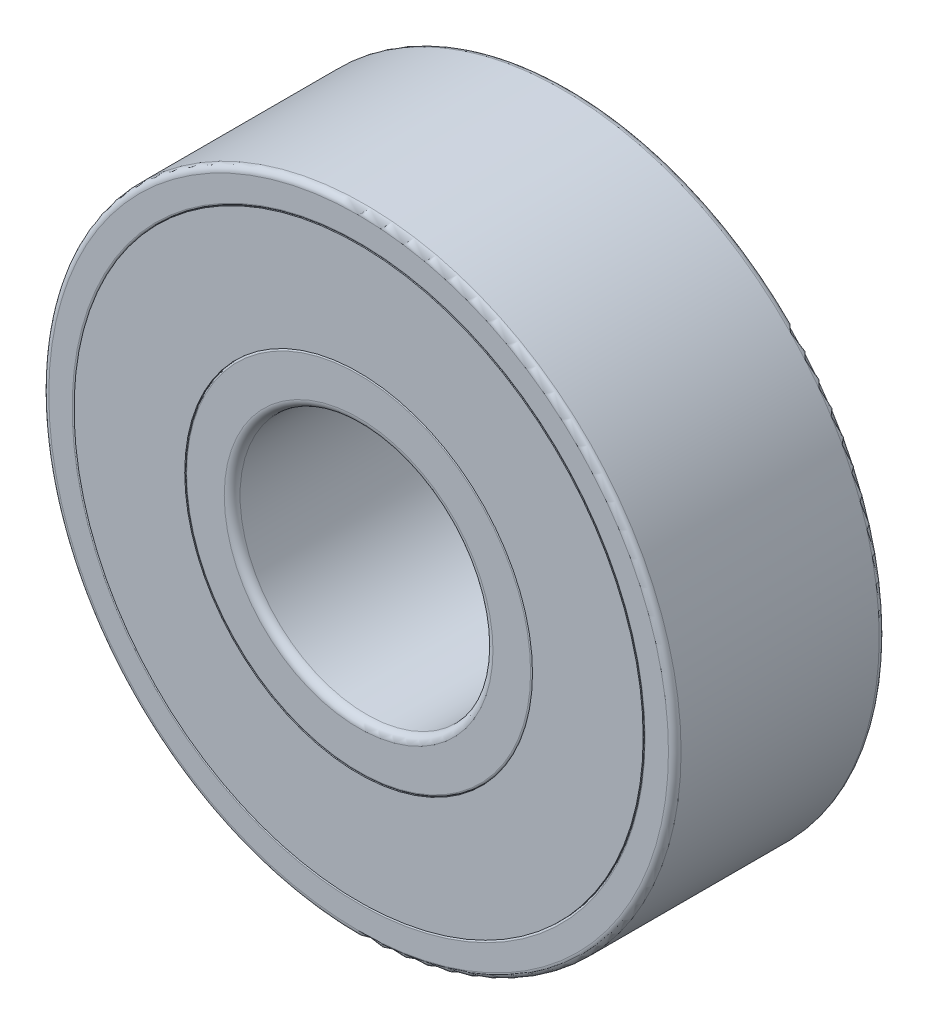
from build123d import *

# Parameters (mm, degrees)
SKETCH3_W           = 5
SKETCH3_H           = 0.75
SKETCH3_H_2         = 1.125
SKETCH4_R           = 1.575
CIRPATTERN1_COUNT   = 7
FILLET1_R           = 0.15
FILLET2_R           = 0.1875
FILLET3_R           = 0.045
FILLET4_R           = 0.045
SKETCH6_R           = 6.75
SKETCH6_R_2         = 4.125
BOSS_EXTRUDE2_DEPTH = 2.5


with BuildPart() as part:
    # Sketch3 → Revolve1 (revolve)
    with BuildSketch(Plane(origin=(0, 0, 0), x_dir=(0, 0, -1), z_dir=(1, 0, 0))):
        with Locations((0, -7.125)):
            Rectangle(SKETCH3_W, SKETCH3_H)
        with Locations((0, -3.5625)):
            Rectangle(SKETCH3_W, SKETCH3_H_2)
    revolve(axis=Axis((0, 0, 2.5), (0, 0, -1)))

    # Sketch4 → Cut-Revolve1 (revolve, cut)
    with BuildSketch(Plane(origin=(0, 0, 0), x_dir=(0, 0, -1), z_dir=(1, 0, 0))):
        with Locations((0, -5.4375)):
            Circle(SKETCH4_R)
    revolve(axis=Axis((0, 0, 2.5), (0, 0, -1)), mode=Mode.SUBTRACT)

    # Fillet1
    fillet1_edges = [part.edges().sort_by_distance(p)[0] for p in [
        (0, 7.5, -2.5),
        (0, 7.5, 2.5),
    ]]
    fillet(fillet1_edges, radius=FILLET1_R)

    # Fillet2
    fillet2_edges = [part.edges().sort_by_distance(p)[0] for p in [
        (0, 3, -2.5),
        (0, 3, 2.5),
    ]]
    fillet(fillet2_edges, radius=FILLET2_R)

    # Fillet3
    fillet3_edges = [part.edges().sort_by_distance(p)[0] for p in [
        (0, 6.75, 2.5),
        (0, 6.75, -2.5),
    ]]
    fillet(fillet3_edges, radius=FILLET3_R)

    # Fillet4
    fillet4_edges = [part.edges().sort_by_distance(p)[0] for p in [
        (0, 4.125, 2.5),
        (0, 4.125, -2.5),
    ]]
    fillet(fillet4_edges, radius=FILLET4_R)


with BuildPart() as body_2:
    # Sketch5 → Revolve2 (revolve)
    with BuildSketch(Plane(origin=(0, 0, 0), x_dir=(0, 0, -1), z_dir=(1, 0, 0))):
        with BuildLine():
            Line((0, -3.8625), (0, -7.0125))
            ThreePointArc((0, -7.0125), (1.575, -5.4375), (0, -3.8625))
        make_face()
    revolve(axis=Axis((0, -3.8625, 0), (0, -1, 0)))


with BuildPart() as cirpattern1_1:
    # CirPattern1: pattern copy
    add(body_2.part.rotate(Axis((0, 0, 0), (0, 0, 1)), 1 * 360 / CIRPATTERN1_COUNT))


with BuildPart() as cirpattern1_2:
    # CirPattern1: pattern copy
    add(body_2.part.rotate(Axis((0, 0, 0), (0, 0, 1)), 2 * 360 / CIRPATTERN1_COUNT))


with BuildPart() as cirpattern1_3:
    # CirPattern1: pattern copy
    add(body_2.part.rotate(Axis((0, 0, 0), (0, 0, 1)), 3 * 360 / CIRPATTERN1_COUNT))


with BuildPart() as cirpattern1_4:
    # CirPattern1: pattern copy
    add(body_2.part.rotate(Axis((0, 0, 0), (0, 0, 1)), 4 * 360 / CIRPATTERN1_COUNT))


with BuildPart() as cirpattern1_5:
    # CirPattern1: pattern copy
    add(body_2.part.rotate(Axis((0, 0, 0), (0, 0, 1)), 5 * 360 / CIRPATTERN1_COUNT))


with BuildPart() as cirpattern1_6:
    # CirPattern1: pattern copy
    add(body_2.part.rotate(Axis((0, 0, 0), (0, 0, 1)), 6 * 360 / CIRPATTERN1_COUNT))


with BuildPart() as body_9:
    # Sketch6 → Boss-Extrude2 (new body, symmetric)
    with BuildSketch(Plane.XY):
        Circle(SKETCH6_R)
        Circle(SKETCH6_R_2, mode=Mode.SUBTRACT)
    extrude(amount=BOSS_EXTRUDE2_DEPTH, both=True)


solid = Compound([part.part, body_2.part, cirpattern1_1.part, cirpattern1_2.part, cirpattern1_3.part, cirpattern1_4.part, cirpattern1_5.part, cirpattern1_6.part, body_9.part])
